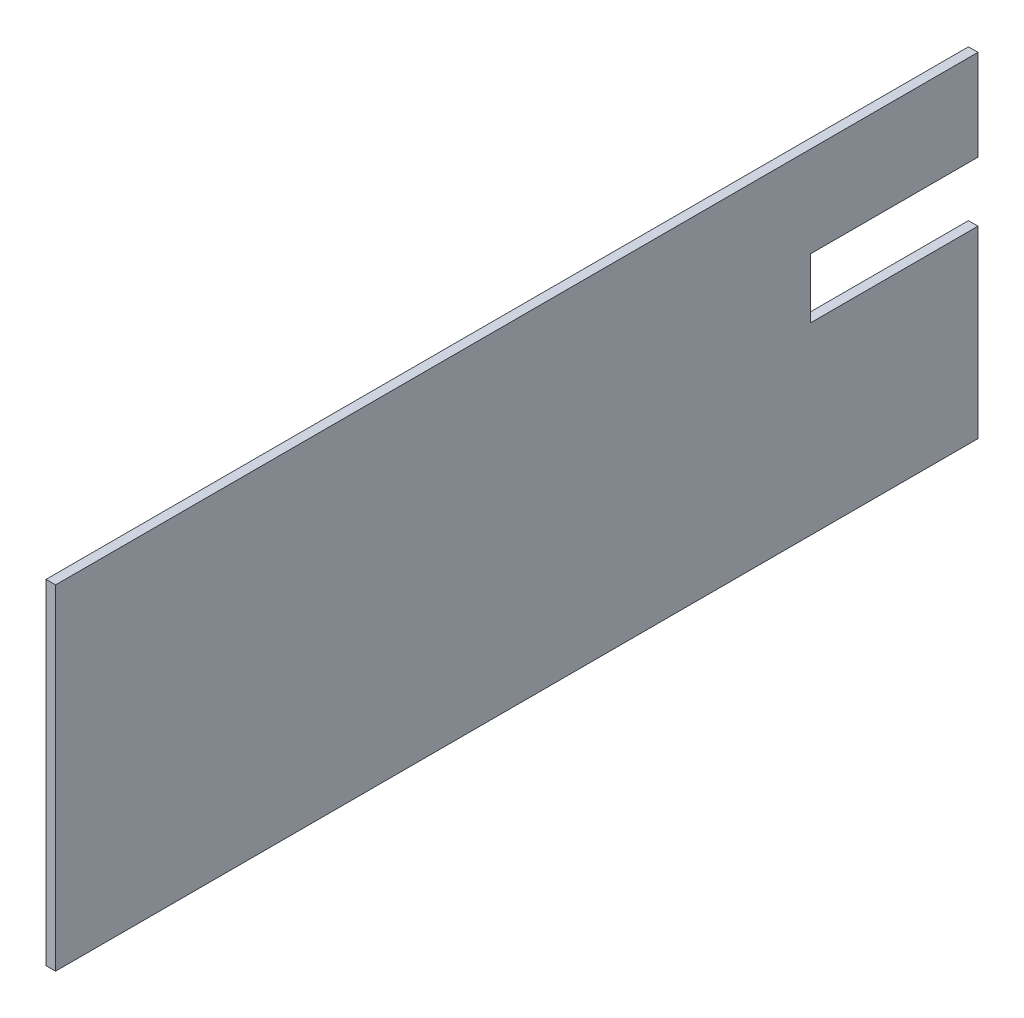
from build123d import *

# Parameters (mm, degrees)
SKETCH1_W           = 193
SKETCH1_H           = 70
BOSS_EXTRUDE1_DEPTH = 35
SKETCH2_W           = 33
SKETCH2_H           = 70
CUT_EXTRUDE1_DEPTH  = 194
SKETCH3_W           = 35
SKETCH3_H           = 12.5
CUT_EXTRUDE2_DEPTH  = 10


with BuildPart() as part:
    # Sketch1 → Boss-Extrude1 (new body)
    with BuildSketch(Plane(origin=(0, 0, 0), x_dir=(0, 0, -1), z_dir=(1, 0, 0))):
        with Locations((96.5, 35)):
            Rectangle(SKETCH1_W, SKETCH1_H)
    extrude(amount=BOSS_EXTRUDE1_DEPTH)

    # Sketch2 → Cut-Extrude1 (cut, through all)
    with BuildSketch(Plane.XY):
        with Locations((16.5, 35)):
            Rectangle(SKETCH2_W, SKETCH2_H)
    extrude(amount=-CUT_EXTRUDE1_DEPTH, mode=Mode.SUBTRACT)

    # Sketch3 → Cut-Extrude2 (cut)
    with BuildSketch(Plane(origin=(35, 0, 0), x_dir=(0, 0, -1), z_dir=(1, 0, 0))):
        with Locations((175.5, 44.75)):
            Rectangle(SKETCH3_W, SKETCH3_H)
    extrude(amount=-CUT_EXTRUDE2_DEPTH, mode=Mode.SUBTRACT)


solid = part.part
